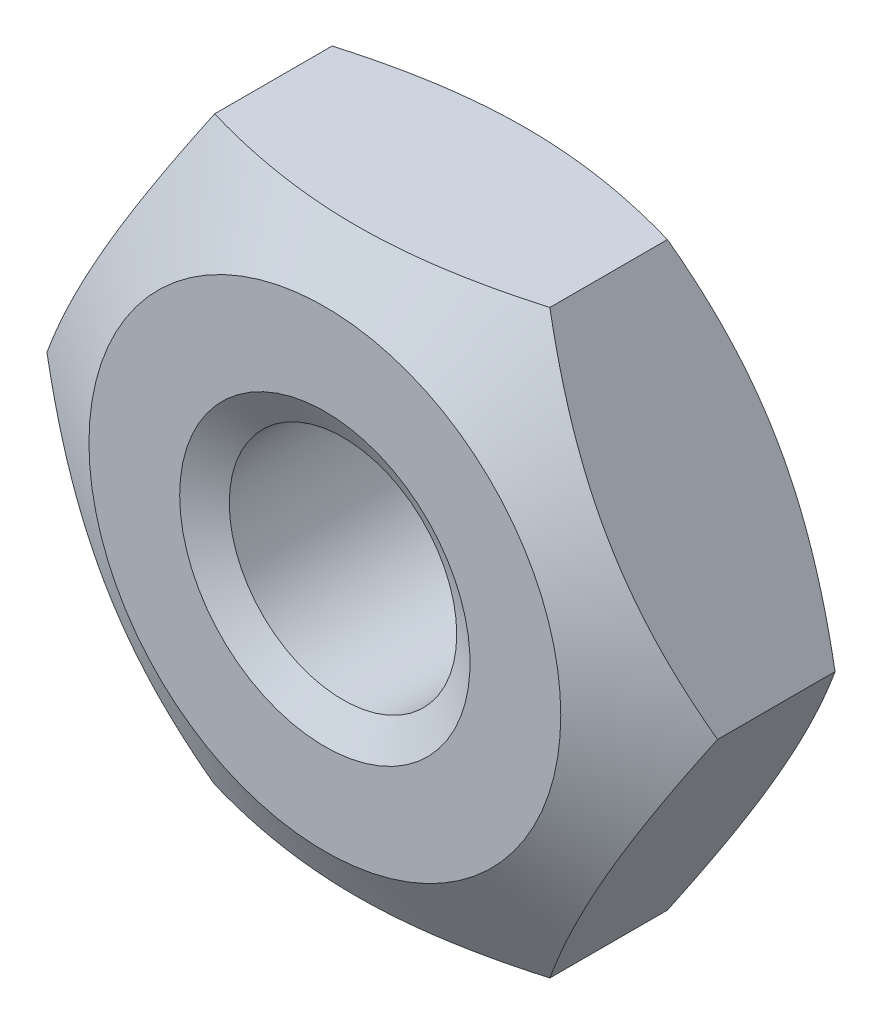
from build123d import *

# Parameters (mm, degrees)
SKETCH1_R               = 0.7835
BASENUT_DEPTH           = 1.6
ENDCHAMFER_SIZE         = 0.2165
ENDCHAMFER_SIZE2        = 0.124996333
ENDCHAMFER_PART_2_SIZE  = 0.2165
ENDCHAMFER_PART_2_SIZE2 = 0.124996333


with BuildPart() as part:
    # Sketch1 → BaseNut (new body)
    with BuildSketch(Plane.XY):
        Polygon((2.309401077, 0), (1.154700538, 2), (-1.154700538, 2), (-2.309401077, 0), (-1.154700538, -2), (1.154700538, -2), align=None)
        Circle(SKETCH1_R, mode=Mode.SUBTRACT)
    extrude(amount=-BASENUT_DEPTH)

    # Sketch2 → Double-Chamfer (revolve, cut)
    with BuildSketch(Plane(origin=(0, 0, 0), x_dir=(1, 0, 0), z_dir=(0, 1, 0))):
        Polygon((-2.309401077, 1.6), (-1.625, 1.6), (-2.309401077, 1.204860854), align=None)
        Polygon((-2.309401077, 0.395139146), (-2.309401077, 0), (-1.625, 0), align=None)
    revolve(axis=Axis((0, 0, -3.375940562), (0, 0, 1)), mode=Mode.SUBTRACT)

    # EndChamfer
    endchamfer_edges = [part.edges().sort_by_distance(p)[0] for p in [
        (-0.7835, 0, -1.6),
    ]]
    endchamfer_side = [part.faces().sort_by_distance(p)[0] for p in [
        (-0.7835, 0, -0.8),
    ]]
    chamfer(endchamfer_edges, length=ENDCHAMFER_SIZE, length2=ENDCHAMFER_SIZE2, reference=endchamfer_side[0])

    # EndChamfer part 2
    endchamfer_part_2_edges = [part.edges().sort_by_distance(p)[0] for p in [
        (-0.7835, 0, 0),
    ]]
    endchamfer_part_2_side = [part.faces().sort_by_distance(p)[0] for p in [
        (1.579038059, 0, 0),
    ]]
    chamfer(endchamfer_part_2_edges, length=ENDCHAMFER_PART_2_SIZE, length2=ENDCHAMFER_PART_2_SIZE2, reference=endchamfer_part_2_side[0])


solid = part.part
